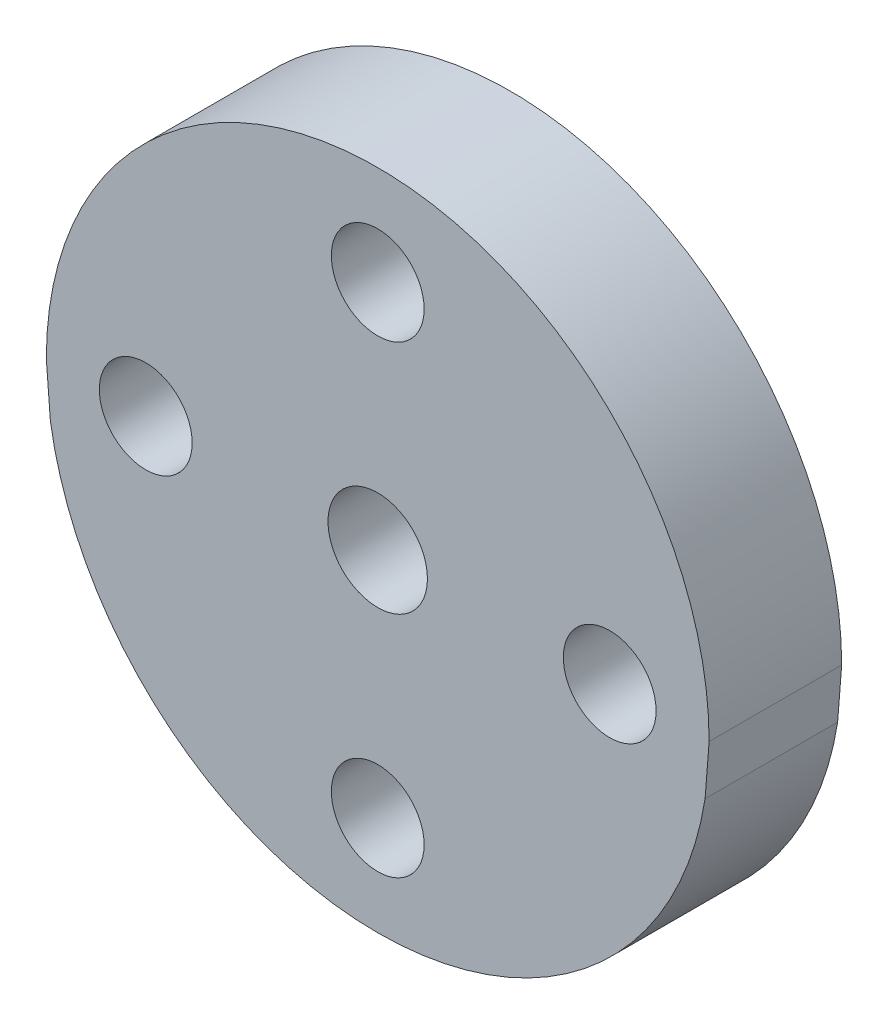
from build123d import *

# Parameters (mm, degrees)
SKETCH1_R           = 1.5
SKETCH1_R_2         = 1.4
BOSS_EXTRUDE1_DEPTH = 4
SKETCH2_R           = 1.4
CUT_EXTRUDE1_DEPTH  = 10


with BuildPart() as part:
    # Sketch1 → Boss-Extrude1 (new body)
    with BuildSketch(Plane.XY):
        with BuildLine():
            Line((-10, 0), (-7.652901889, -30))
            ThreePointArc((-7.652901889, -30), (0, -37.652901889), (7.652901889, -30))
            Line((7.652901889, -30), (10, 0))
            ThreePointArc((10, 0), (0, 10), (-10, 0))
        make_face()
        Circle(SKETCH1_R, mode=Mode.SUBTRACT)
        with Locations((7, 0)):
            Circle(SKETCH1_R_2, mode=Mode.SUBTRACT)
        with Locations((0, -7)):
            Circle(SKETCH1_R_2, mode=Mode.SUBTRACT)
        with Locations((-7, 0)):
            Circle(SKETCH1_R_2, mode=Mode.SUBTRACT)
        with Locations((0, 7)):
            Circle(SKETCH1_R_2, mode=Mode.SUBTRACT)
        with Locations((0, -30)):
            Circle(SKETCH1_R_2, mode=Mode.SUBTRACT)
    extrude(amount=BOSS_EXTRUDE1_DEPTH)

    # Sketch2 → Cut-Extrude1 (cut)
    with BuildSketch(Plane.XY.offset(4)):
        with BuildLine():
            ThreePointArc((9.878325443, -1.55521267), (0, -10), (-9.878325443, -1.55521267))
            Line((-9.878325443, -1.55521267), (-7.652901889, -30))
            ThreePointArc((-7.652901889, -30), (0, -37.652901889), (7.652901889, -30))
            Line((7.652901889, -30), (9.878325443, -1.55521267))
        make_face()
        with Locations((0, -30)):
            Circle(SKETCH2_R, mode=Mode.SUBTRACT)
    extrude(amount=-CUT_EXTRUDE1_DEPTH, mode=Mode.SUBTRACT)


solid = part.part
